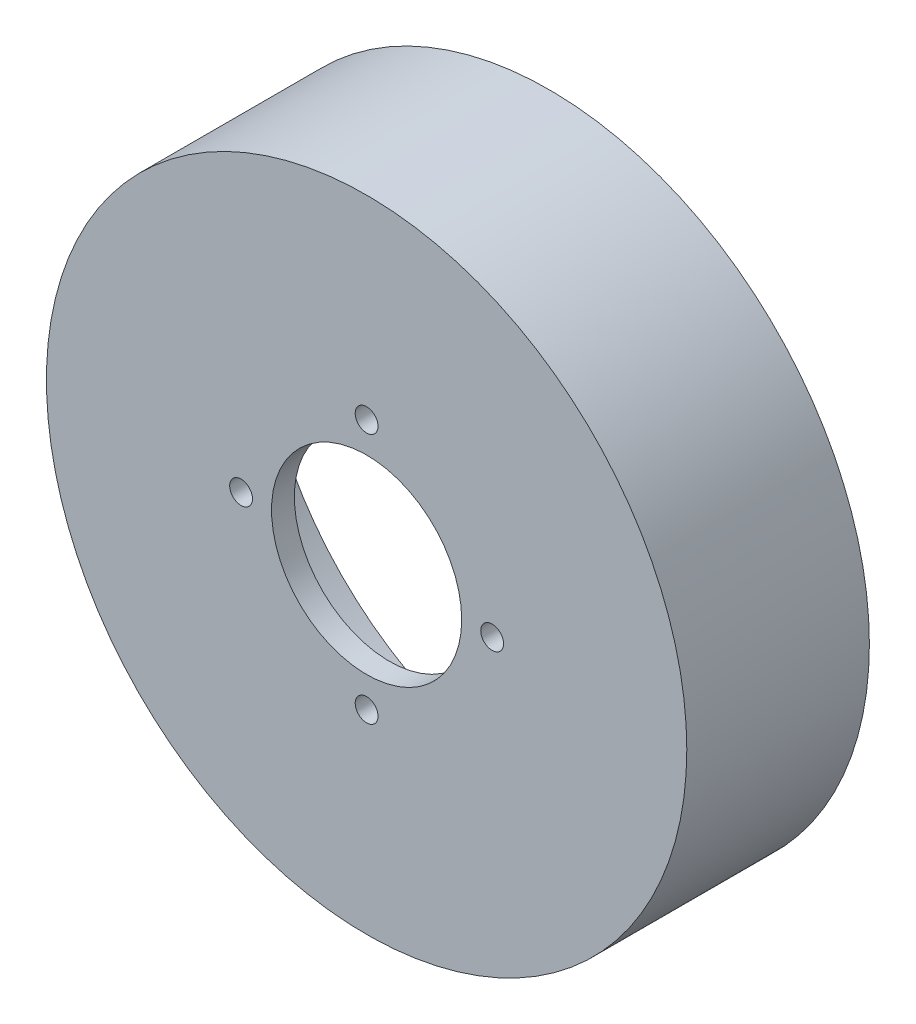
from build123d import *

# Parameters (mm, degrees)
SKETCH1_R               = 42.0875
BOSS_EXTRUDE1_DEPTH     = 24
SKETCH2_R               = 38.2875
CUT_EXTRUDE1_DEPTH      = 11
SKETCH3_R               = 34.2875
CUT_EXTRUDE2_DEPTH      = 10
SKETCH5_R               = 12.5
CUT_EXTRUDE4_DEPTH      = 1
CUT_EXTRUDE4_DEPTH_BACK = 25
CUT_EXTRUDE3_START      = -4
SKETCH4_R               = 1.5
CUT_EXTRUDE3_DEPTH      = 26
CIRPATTERN1_COUNT       = 4


with BuildPart() as part:
    # Sketch1 → Boss-Extrude1 (new body)
    with BuildSketch(Plane.XY.offset(-8)):
        Circle(SKETCH1_R)
    extrude(amount=BOSS_EXTRUDE1_DEPTH)

    # Sketch2 → Cut-Extrude1 (cut)
    with BuildSketch(Plane(origin=(0, 0, -8), x_dir=(-1, 0, 0), z_dir=(0, 0, -1))):
        Circle(SKETCH2_R)
    extrude(amount=-CUT_EXTRUDE1_DEPTH, mode=Mode.SUBTRACT)

    # Sketch3 → Cut-Extrude2 (cut)
    with BuildSketch(Plane(origin=(0, 0, 3), x_dir=(-1, 0, 0), z_dir=(0, 0, -1))):
        Circle(SKETCH3_R)
    extrude(amount=-CUT_EXTRUDE2_DEPTH, mode=Mode.SUBTRACT)

    # Sketch5 → Cut-Extrude4 (cut, two sides)
    with BuildSketch(Plane.XY.offset(16)) as cut_extrude4_sk:
        Circle(SKETCH5_R)
    extrude(amount=CUT_EXTRUDE4_DEPTH, mode=Mode.SUBTRACT)
    extrude(cut_extrude4_sk.sketch, amount=-CUT_EXTRUDE4_DEPTH_BACK, mode=Mode.SUBTRACT)

    # Sketch4 → Cut-Extrude3 (cut)
    with BuildSketch(Plane(origin=(0, 0, 13), x_dir=(-1, 0, 0), z_dir=(0, 0, -1)).offset(CUT_EXTRUDE3_START)):
        with Locations((-16.5, 0)):
            Circle(SKETCH4_R)
    cut_extrude3 = extrude(amount=CUT_EXTRUDE3_DEPTH, mode=Mode.SUBTRACT)

    # CirPattern1: Cut-Extrude3 ×4 about axis
    cirpattern1_axis = Axis((0, 0, 0), (0, 0, 1))
    for i in range(1, CIRPATTERN1_COUNT):
        add(cut_extrude3.rotate(cirpattern1_axis, i * 360 / CIRPATTERN1_COUNT), mode=Mode.SUBTRACT)


solid = part.part
